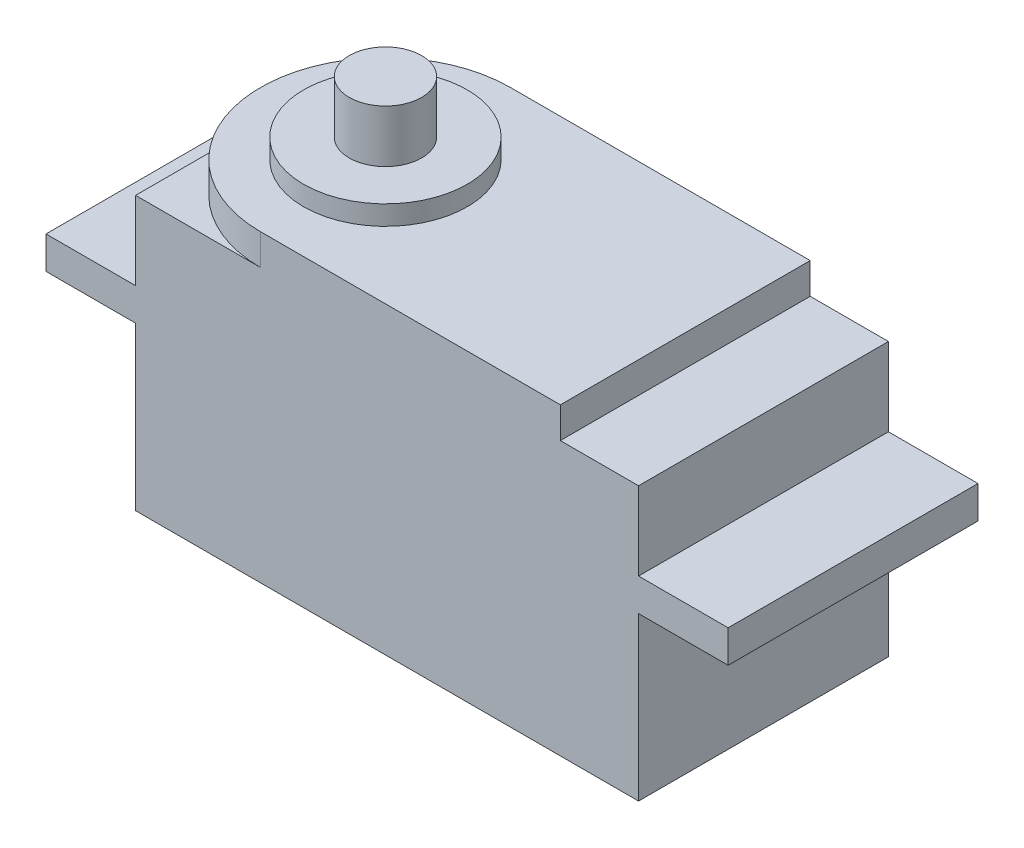
from build123d import *

# Parameters (mm, degrees)
SKETCH1_W           = 40.26
SKETCH1_H           = 20
BOSS_EXTRUDE1_DEPTH = 36.86
SKETCH2_W           = 20
SKETCH2_H           = 2.6
BOSS_EXTRUDE2_DEPTH = 7.17
SKETCH3_W           = 20
SKETCH3_H           = 2.6
BOSS_EXTRUDE3_DEPTH = 7.17
SKETCH4_R           = 10
BOSS_EXTRUDE4_DEPTH = 2.48
SKETCH5_R           = 6.55
BOSS_EXTRUDE5_DEPTH = 1.56
SKETCH6_R           = 2.9
BOSS_EXTRUDE6_DEPTH = 4.2
SKETCH7_W           = 40.26
SKETCH7_H           = 20
CUT_EXTRUDE1_DEPTH  = 15


with BuildPart() as part:
    # Sketch1 → Boss-Extrude1 (new body)
    with BuildSketch(Plane(origin=(0, 0, 0), x_dir=(1, 0, 0), z_dir=(0, 1, 0))):
        Rectangle(SKETCH1_W, SKETCH1_H)
    extrude(amount=BOSS_EXTRUDE1_DEPTH)

    # Sketch2 → Boss-Extrude2 (add)
    with BuildSketch(Plane(origin=(20.13, 0, 0), x_dir=(0, 0, -1), z_dir=(1, 0, 0))):
        with Locations((0, 29.3)):
            Rectangle(SKETCH2_W, SKETCH2_H)
    extrude(amount=BOSS_EXTRUDE2_DEPTH)

    # Sketch3 → Boss-Extrude3 (add)
    with BuildSketch(Plane.ZY.offset(20.13)):
        with Locations((0, 29.3)):
            Rectangle(SKETCH3_W, SKETCH3_H)
    extrude(amount=BOSS_EXTRUDE3_DEPTH)

    # Sketch4 → Boss-Extrude4 (add)
    with BuildSketch(Plane(origin=(0, 36.86, 0), x_dir=(1, 0, 0), z_dir=(0, 1, 0))):
        with Locations((-10.13, 0)):
            Circle(SKETCH4_R)
        with BuildLine():
            Line((13.87, 10), (-10.13, 10))
            ThreePointArc((-10.13, 10), (-3.058932188, 7.071067812), (-0.13, 0))
            ThreePointArc((-0.13, 0), (-3.058932188, -7.071067812), (-10.13, -10))
            Line((-10.13, -10), (13.87, -10))
            Line((13.87, -10), (13.87, 10))
        make_face()
    extrude(amount=BOSS_EXTRUDE4_DEPTH)

    # Sketch5 → Boss-Extrude5 (add)
    with BuildSketch(Plane(origin=(0, 39.34, 0), x_dir=(1, 0, 0), z_dir=(0, 1, 0))):
        with Locations((-10.13, 0)):
            Circle(SKETCH5_R)
    extrude(amount=BOSS_EXTRUDE5_DEPTH)

    # Sketch6 → Boss-Extrude6 (add)
    with BuildSketch(Plane(origin=(0, 40.9, 0), x_dir=(1, 0, 0), z_dir=(0, 1, 0))):
        with Locations((-10.13, 0)):
            Circle(SKETCH6_R)
    extrude(amount=BOSS_EXTRUDE6_DEPTH)

    # Sketch7 → Cut-Extrude1 (cut)
    with BuildSketch(Plane.XZ):
        Rectangle(SKETCH7_W, SKETCH7_H)
    extrude(amount=-CUT_EXTRUDE1_DEPTH, mode=Mode.SUBTRACT)


solid = part.part
